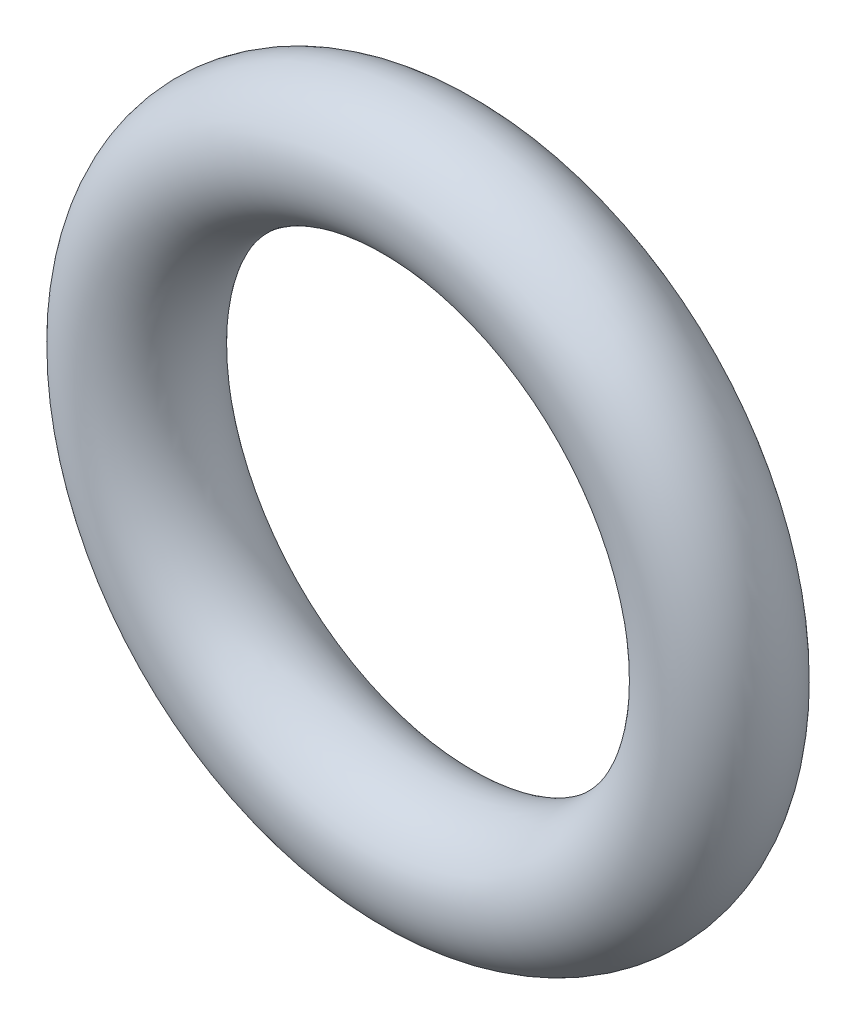
from build123d import *

# Parameters (mm, degrees)
SKETCH2_R = 0.95


with BuildPart() as part:
    # Sweep1: sweep along a path in Sketch1
    with BuildLine(Plane.XY) as sweep1_path:
        CenterArc((0, 0), 3.4, 0, 360)
    # Sketch2 → Sweep1 (sweep)
    with BuildSketch(Plane(origin=(0, 0, 0), x_dir=(1, 0, 0), z_dir=(0, 1, 0))):
        with Locations((-4.35, 0)):
            Circle(SKETCH2_R)
    sweep(path=sweep1_path.line)


solid = part.part
